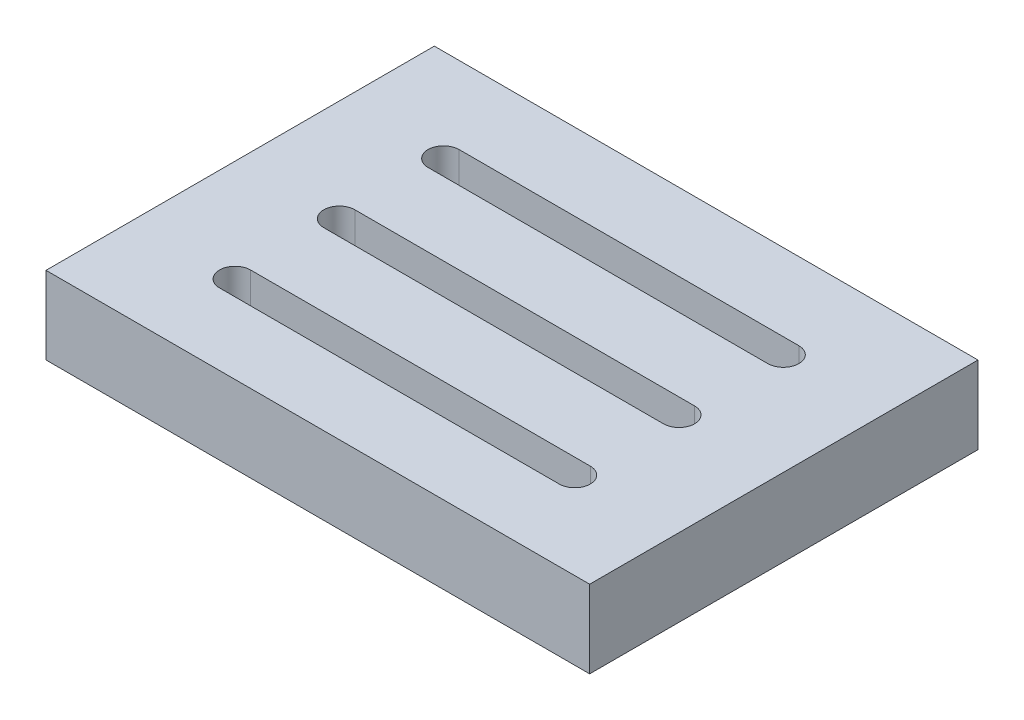
from build123d import *

# Parameters (mm, degrees)
SKETCH1_W           = 70
SKETCH1_H           = 50
BOSS_EXTRUDE1_DEPTH = 10
CUT_EXTRUDE1_DEPTH  = 10


with BuildPart() as part:
    # Sketch1 → Boss-Extrude1 (new body)
    with BuildSketch(Plane(origin=(0, 0, 0), x_dir=(1, 0, 0), z_dir=(0, 1, 0))):
        Rectangle(SKETCH1_W, SKETCH1_H)
    extrude(amount=BOSS_EXTRUDE1_DEPTH)

    # Sketch2 → Cut-Extrude1 (cut)
    with BuildSketch(Plane(origin=(0, 10, 0), x_dir=(1, 0, 0), z_dir=(0, 1, 0))):
        with BuildLine():
            Line((-21.871185968, 15.064337274), (21.871185968, 15.064337274))
            ThreePointArc((21.871185968, 15.064337274), (23.871185968, 13.064337274), (21.871185968, 11.064337274))
            Line((21.871185968, 11.064337274), (-21.871185968, 11.064337274))
            ThreePointArc((-21.871185968, 11.064337274), (-23.871185968, 13.064337274), (-21.871185968, 15.064337274))
        make_face()
        with BuildLine():
            Line((-21.871185968, -11.791098557), (21.871185968, -11.791098557))
            ThreePointArc((21.871185968, -11.791098557), (23.871185968, -13.791098557), (21.871185968, -15.791098557))
            Line((21.871185968, -15.791098557), (-21.871185968, -15.791098557))
            ThreePointArc((-21.871185968, -15.791098557), (-23.871185968, -13.791098557), (-21.871185968, -11.791098557))
        make_face()
        with BuildLine():
            Line((-21.871185968, 1.636619358), (21.871185968, 1.636619358))
            ThreePointArc((21.871185968, 1.636619358), (23.871185968, -0.363380642), (21.871185968, -2.363380642))
            Line((21.871185968, -2.363380642), (-21.871185968, -2.363380642))
            ThreePointArc((-21.871185968, -2.363380642), (-23.871185968, -0.363380642), (-21.871185968, 1.636619358))
        make_face()
    extrude(amount=-CUT_EXTRUDE1_DEPTH, mode=Mode.SUBTRACT)


solid = part.part
